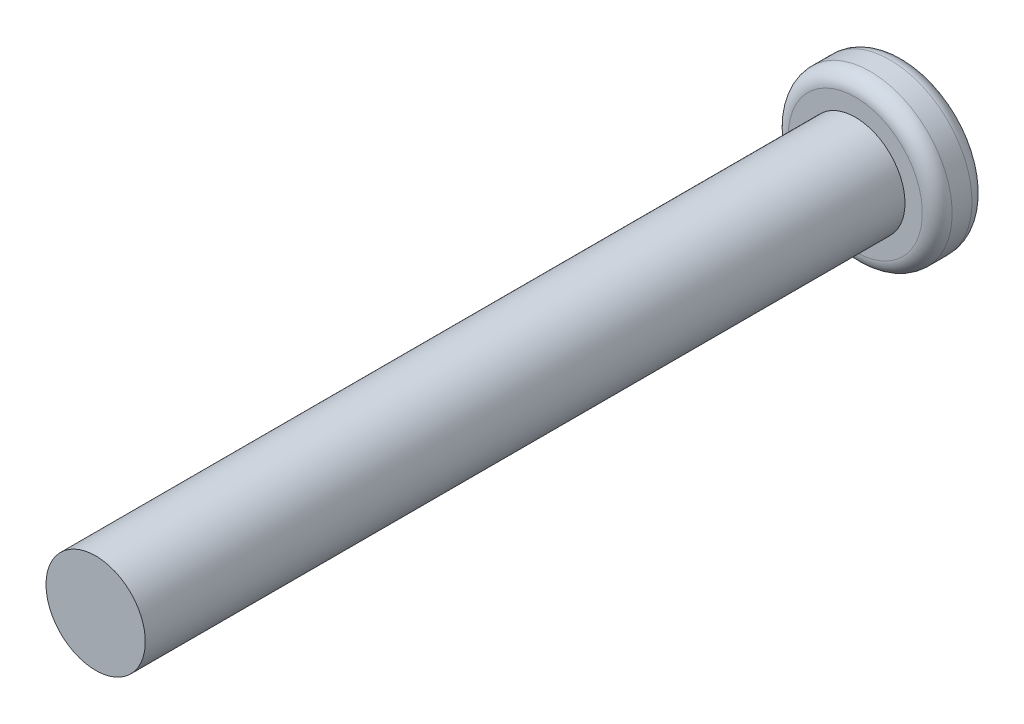
from build123d import *


with BuildPart() as part:
    # Sketch1 → Revolve1 (revolve)
    with BuildSketch(Plane.XZ):
        with BuildLine():
            Line((10, 223), (0, 223))
            Line((0, 223), (0, 63))
            Line((0, 63), (10, 63))
            ThreePointArc((10, 63), (10.878679656, 60.878679656), (13, 60))
            Line((13, 60), (13.5, 60))
            ThreePointArc((13.5, 60), (15.621320344, 60.878679656), (16.5, 63))
            Line((16.5, 63), (16.5, 67))
            ThreePointArc((16.5, 67), (15.621320344, 69.121320344), (13.5, 70))
            Line((13.5, 70), (10, 70))
            Line((10, 70), (10, 223))
        make_face()
    revolve(axis=Axis((0, 0, 223), (0, 0, -1)))


solid = part.part
